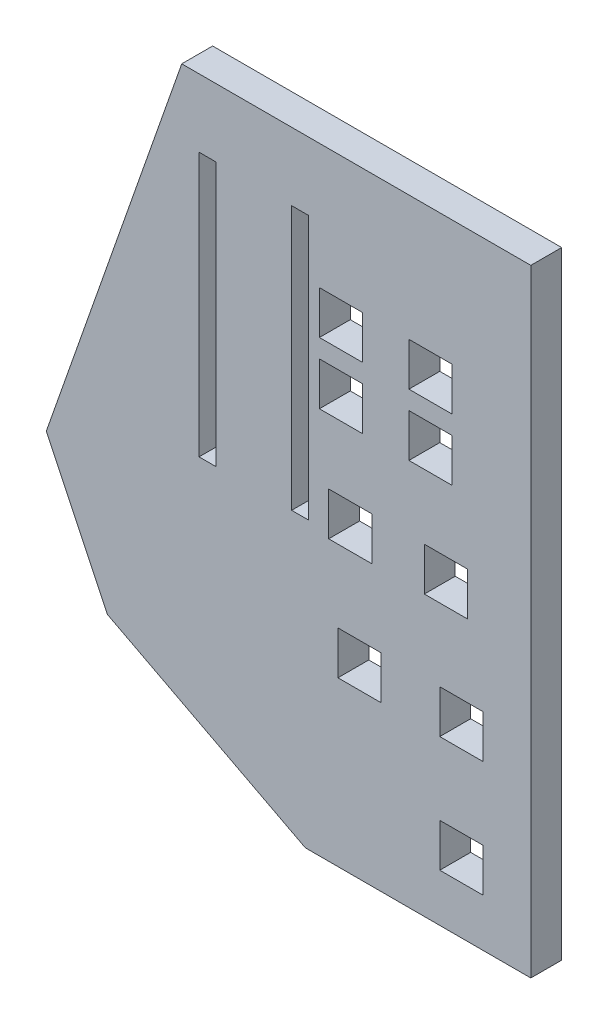
from build123d import *

# Parameters (mm, degrees)
BOSS_EXTRUDE1_DEPTH = 5.08
SKETCH5_W           = 7.112
SKETCH5_H           = 7.112
SKETCH5_W_2         = 2.794
SKETCH5_H_2         = 43.434
CUT_EXTRUDE1_DEPTH  = 6.08


with BuildPart() as part:
    # Sketch1 → Boss-Extrude1 (new body)
    with BuildSketch(Plane.XY):
        Polygon((-4.120444444, 6.35), (53.34, 6.35), (53.34, -95.25), (16.22499019, -95.25), (-16.356614113, -78.274710363), (-26.416, -57.15), align=None)
    extrude(amount=BOSS_EXTRUDE1_DEPTH)

    # Sketch5 → Cut-Extrude1 (cut, through all)
    with BuildSketch(Plane(origin=(0, 0, 0), x_dir=(-1, 0, 0), z_dir=(0, 0, -1))):
        with Locations((-36.83, -17.78)):
            Rectangle(SKETCH5_W, SKETCH5_H)
        with Locations((-39.37, -45.72)):
            Rectangle(SKETCH5_W, SKETCH5_H)
        with Locations((-36.83, -27.94)):
            Rectangle(SKETCH5_W, SKETCH5_H)
        with Locations((-41.91, -64.77)):
            Rectangle(SKETCH5_W, SKETCH5_H)
        with Locations((-41.91, -83.82)):
            Rectangle(SKETCH5_W, SKETCH5_H)
        with Locations((-22.098, -17.78)):
            Rectangle(SKETCH5_W, SKETCH5_H)
        with Locations((-22.098, -27.94)):
            Rectangle(SKETCH5_W, SKETCH5_H)
        with Locations((-23.622, -45.72)):
            Rectangle(SKETCH5_W, SKETCH5_H)
        with Locations((-25.146, -64.77)):
            Rectangle(SKETCH5_W, SKETCH5_H)
        with Locations((-15.367, -26.543)):
            Rectangle(SKETCH5_W_2, SKETCH5_H_2)
        with Locations((-0.127, -26.543)):
            Rectangle(SKETCH5_W_2, SKETCH5_H_2)
    extrude(amount=-CUT_EXTRUDE1_DEPTH, mode=Mode.SUBTRACT)


solid = part.part
